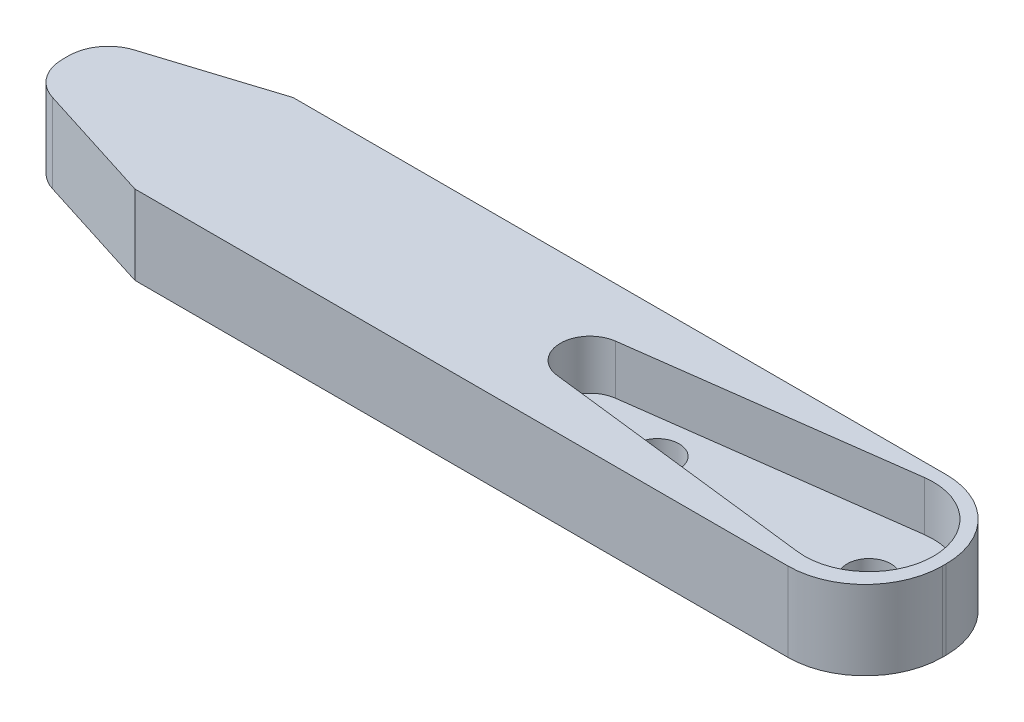
from build123d import *

# Parameters (mm, degrees)
EXTRUDE_1_DEPTH     = 4
CUT_EXTRUDE_1_DEPTH = 2.5
SKETCH_4_R          = 1.1
CUT_EXTRUDE_2_DEPTH = 1


with BuildPart() as part:
    # 草图1 → 凸台-拉伸1 (new body)
    with BuildSketch(Plane(origin=(0, 0, 0), x_dir=(1, 0, 0), z_dir=(0, 1, 0))):
        with BuildLine():
            Line((-22.006488129, 2.068420622), (-15.9, 4))
            Line((-15.9, 4), (17.1, 4))
            ThreePointArc((17.1, 4), (19.857716447, 2.857716447), (21, 0.1))
            Line((21, 0.1), (21, -0.1))
            ThreePointArc((21, -0.1), (19.857716447, -2.857716447), (17.1, -4))
            Line((17.1, -4), (-15.9, -4))
            Line((-15.9, -4), (-22.006488129, -2.068420622))
            ThreePointArc((-22.006488129, -2.068420622), (-23.016748562, -1.343417075), (-23.403312634, -0.161543771))
            Line((-23.403312634, -0.161543771), (-23.403312634, 0.161543771))
            ThreePointArc((-23.403312634, 0.161543771), (-23.016748562, 1.343417075), (-22.006488129, 2.068420622))
        make_face()
    extrude(amount=EXTRUDE_1_DEPTH)

    # 草图2 → 切除-拉伸1 (cut)
    with BuildSketch(Plane(origin=(0, 4, 0), x_dir=(1, 0, 0), z_dir=(0, 1, 0))):
        with BuildLine():
            Line((2.901879582, 1.486858534), (16.670739094, 3.321526824))
            ThreePointArc((16.670739094, 3.321526824), (20.349917095, 0.123213694), (16.716802358, -3.127330099))
            Line((16.716802358, -3.127330099), (2.92313955, -1.489536969))
            ThreePointArc((2.92313955, -1.489536969), (1.600038264, -0.010714012), (2.901879582, 1.486858534))
        make_face()
    extrude(amount=-CUT_EXTRUDE_1_DEPTH, mode=Mode.SUBTRACT)

    # 草图4 → 切除-拉伸2 (cut)
    with BuildSketch(Plane(origin=(0, 1.5, 0), x_dir=(1, 0, 0), z_dir=(0, 1, 0))):
        with Locations((17.1, 0.1)):
            Circle(SKETCH_4_R)
        with Locations((6.5, 0)):
            Circle(SKETCH_4_R)
    extrude(amount=-CUT_EXTRUDE_2_DEPTH, mode=Mode.SUBTRACT)


solid = part.part
